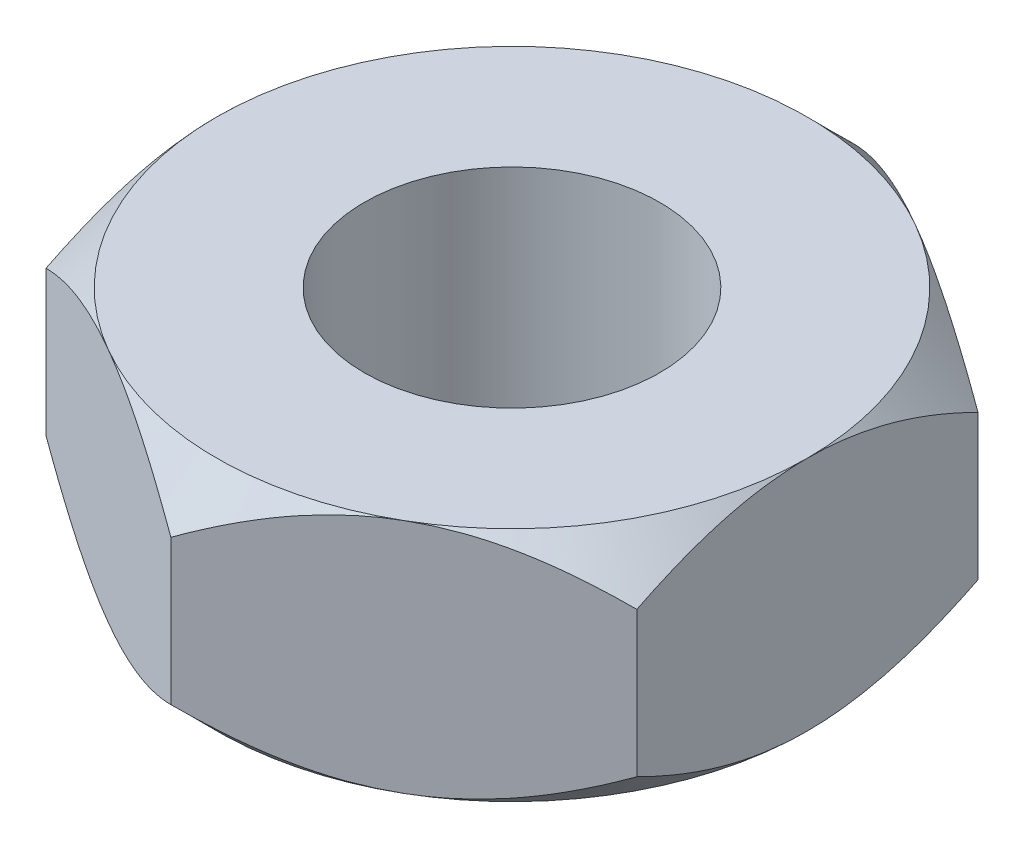
from build123d import *

# Parameters (mm, degrees)
SKETCH1_R           = 1
BOSS_EXTRUDE1_DEPTH = 1.6
SKETCH2_OUTSIDE_W   = 12.464
SKETCH2_OUTSIDE_H   = 13.082
SKETCH2_OUTSIDE_R   = 2
CUT_EXTRUDE1_DEPTH  = 2.6
CUT_EXTRUDE1_TAPER  = 45
SKETCH3_OUTSIDE_W   = 12.464
SKETCH3_OUTSIDE_H   = 13.082
SKETCH3_OUTSIDE_R   = 2
CUT_EXTRUDE2_DEPTH  = 2.6
CUT_EXTRUDE2_TAPER  = 45


with BuildPart() as part:
    # Sketch1 → Boss-Extrude1 (new body)
    with BuildSketch(Plane(origin=(0, 0, 0), x_dir=(1, 0, 0), z_dir=(0, 1, 0))):
        Polygon((0, 2.309401077), (-2, 1.154700538), (-2, -1.154700538), (0, -2.309401077), (2, -1.154700538), (2, 1.154700538), align=None)
        Circle(SKETCH1_R, mode=Mode.SUBTRACT)
    extrude(amount=BOSS_EXTRUDE1_DEPTH)

    # Sketch2 outside → Cut-Extrude1 (cut, through all)
    with BuildSketch(Plane(origin=(0, 1.6, 0), x_dir=(1, 0, 0), z_dir=(0, 1, 0))):
        Rectangle(SKETCH2_OUTSIDE_W, SKETCH2_OUTSIDE_H)
        Circle(SKETCH2_OUTSIDE_R, mode=Mode.SUBTRACT)
    extrude(amount=-CUT_EXTRUDE1_DEPTH, taper=CUT_EXTRUDE1_TAPER, mode=Mode.SUBTRACT)

    # Sketch3 outside → Cut-Extrude2 (cut, through all)
    with BuildSketch(Plane.XZ):
        Rectangle(SKETCH3_OUTSIDE_W, SKETCH3_OUTSIDE_H)
        Circle(SKETCH3_OUTSIDE_R, mode=Mode.SUBTRACT)
    extrude(amount=-CUT_EXTRUDE2_DEPTH, taper=CUT_EXTRUDE2_TAPER, mode=Mode.SUBTRACT)


solid = part.part
